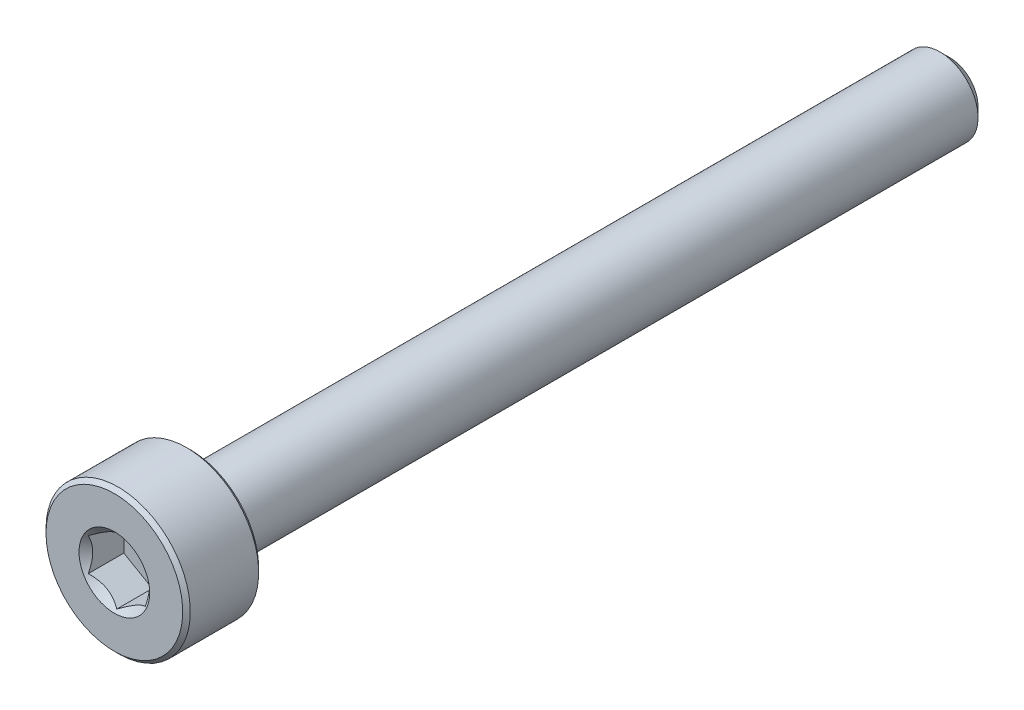
from build123d import *

# Parameters (mm, degrees)
CUT_EXTRUDE1_DEPTH = 1
SKETCH4_R          = 0.930977309
CUT_EXTRUDE2_DEPTH = 1
CUT_EXTRUDE2_DRAFT = -45


with BuildPart() as part:
    # Sketch2 → Revolve1 (revolve)
    with BuildSketch(Plane(origin=(0, 0, 0), x_dir=(0, 0, -1), z_dir=(1, 0, 0))):
        with BuildLine():
            Line((-11, 0), (-11, 1.8))
            Line((-11, 1.8), (-10.9, 1.9))
            Line((-10.9, 1.9), (-9.1, 1.9))
            Line((-9.1, 1.9), (-9, 1.8))
            Line((-9, 1.8), (-9, 1.1))
            ThreePointArc((-9, 1.1), (-8.970710678, 1.029289322), (-8.9, 1))
            Line((-8.9, 1), (10.740192379, 1))
            Line((10.740192379, 1), (11, 0.740192379))
            Line((11, 0.740192379), (11, 0))
            Line((11, 0), (-11, 0))
        make_face()
    revolve(axis=Axis((0, 0, -11), (0, 0, 1)))

    # Sketch3 → Cut-Extrude1 (cut)
    with BuildSketch(Plane.XY.offset(11)):
        Polygon((0.75, -0.433012702), (0.75, 0.433012702), (0, 0.866025404), (-0.75, 0.433012702), (-0.75, -0.433012702), (0, -0.866025404), align=None)
    extrude(amount=-CUT_EXTRUDE1_DEPTH, mode=Mode.SUBTRACT)


with BuildPart() as cut_extrude2_tool:
    # Sketch4 → Cut-Extrude2 (with draft: the straight prism first)
    with BuildSketch(Plane.XY.offset(11)):
        Circle(SKETCH4_R)
    extrude(amount=-CUT_EXTRUDE2_DEPTH)
    # Cut-Extrude2: the draft: its side faces are tilted about the plane it starts from
    cut_extrude2_sides = [cut_extrude2_tool.faces().sort_by_distance(p)[0] for p in [
        (-0.930977309, 0, 10.5),
    ]]
    draft(cut_extrude2_sides, Plane.XY.offset(11), CUT_EXTRUDE2_DRAFT)


with BuildPart() as part_1:
    add(part.part)

    # Cut-Extrude2: cut by cut_extrude2_tool
    add(cut_extrude2_tool.part, mode=Mode.SUBTRACT)


solid = part_1.part
